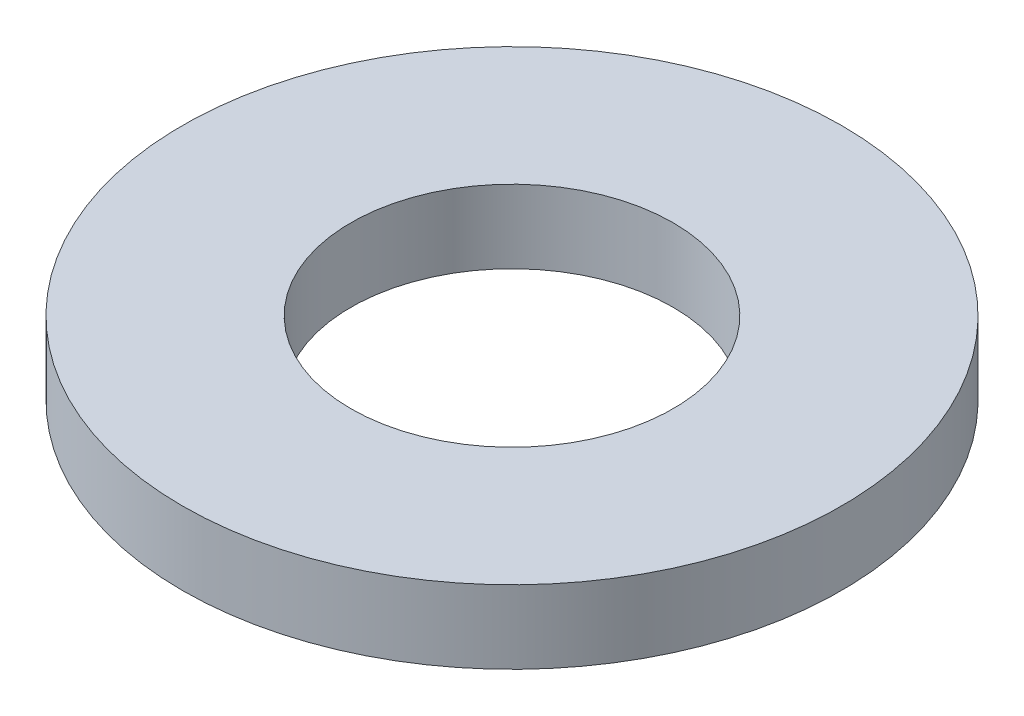
from build123d import *

# Parameters (mm, degrees)
SKICA1_R                = 2.25
SKICA1_R_2              = 1.1
P_IDAT_VYSUNUT_M1_DEPTH = 0.5


with BuildPart() as part:
    # Skica1 → Přidat vysunutím1 (new body)
    with BuildSketch(Plane(origin=(0, 0, 0), x_dir=(1, 0, 0), z_dir=(0, 1, 0))):
        Circle(SKICA1_R)
        Circle(SKICA1_R_2, mode=Mode.SUBTRACT)
    extrude(amount=P_IDAT_VYSUNUT_M1_DEPTH)


solid = part.part
